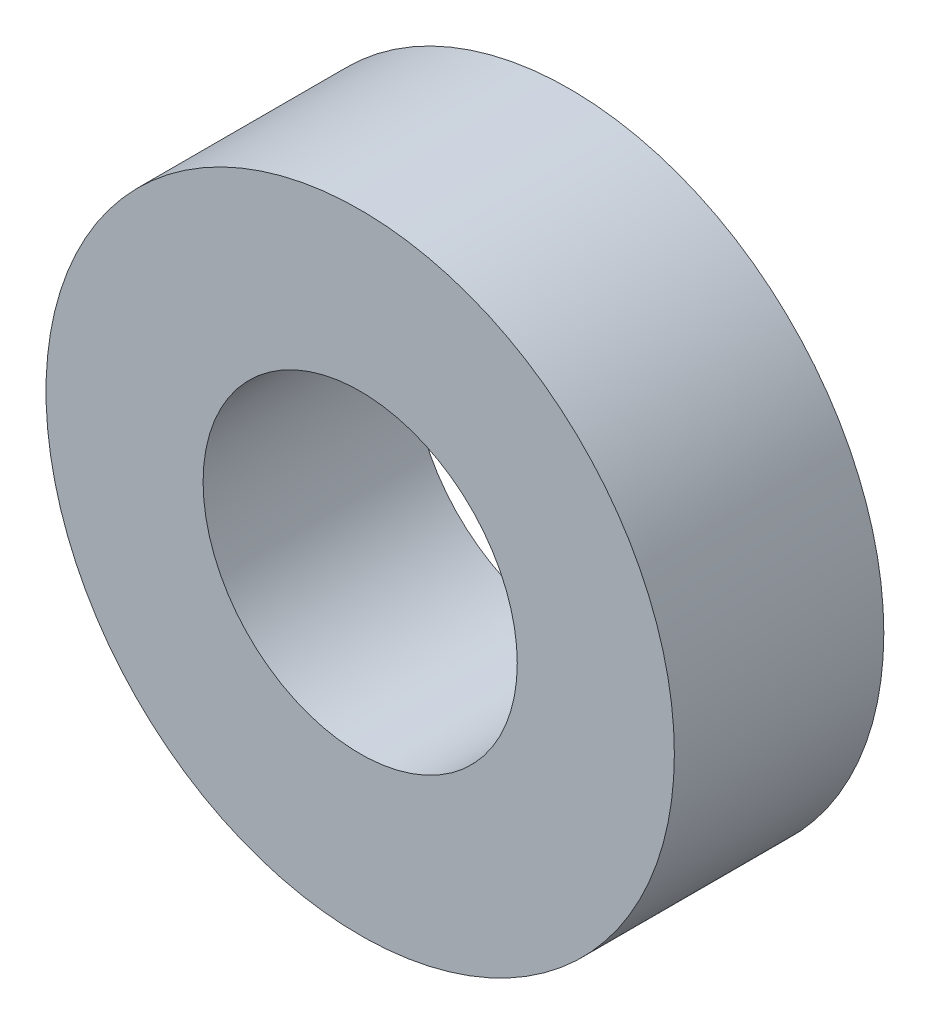
from build123d import *

# Parameters (mm, degrees)
SKETCH1_R           = 3
SKETCH1_R_2         = 1.5
BOSS_EXTRUDE1_DEPTH = 2


with BuildPart() as part:
    # Sketch1 → Boss-Extrude1 (new body)
    with BuildSketch(Plane.XY):
        Circle(SKETCH1_R)
        Circle(SKETCH1_R_2, mode=Mode.SUBTRACT)
    extrude(amount=BOSS_EXTRUDE1_DEPTH)


solid = part.part
